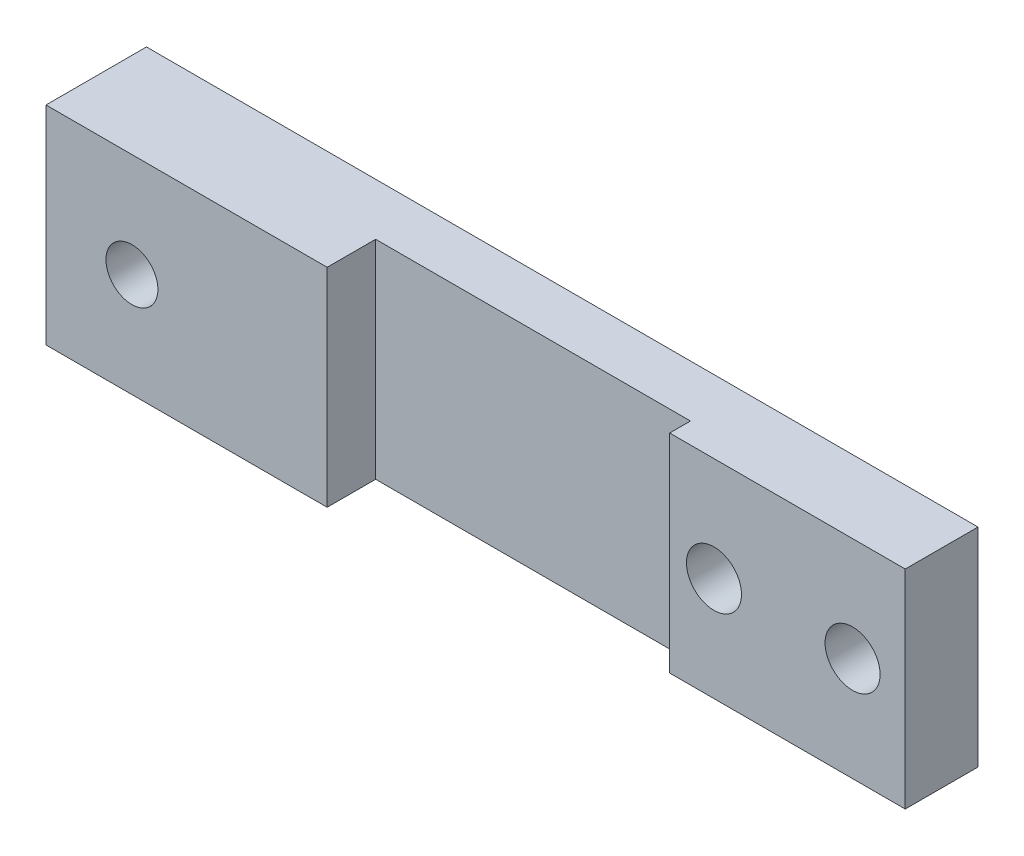
from build123d import *

# Parameters (mm, degrees)
SKETCH1_W                        = 152.4
SKETCH1_H                        = 38.1
BOSS_EXTRUDE1_DEPTH              = 9.525
SKETCH5_W                        = 43.18
SKETCH5_H                        = 38.1
BOSS_EXTRUDE3_DEPTH              = 3.81
SKETCH3_W                        = 5.0419
SKETCH3_H                        = 3.81
F_3_8_CLEARANCE_HOLE1_AT_2_COUNT = 2
F_3_8_CLEARANCE_HOLE1_AT_2_PITCH = 25.4
SKETCH4_W                        = 51.528477944
SKETCH4_H                        = 38.1
BOSS_EXTRUDE2_DEPTH              = 8.89
F_3_8_CLEARANCE_HOLE3_D          = 10.0838
SKETCH10_R                       = 4.7625
CUT_EXTRUDE1_DEPTH               = 19.415


with BuildPart() as part:
    # Sketch1 → Boss-Extrude1 (new body)
    with BuildSketch(Plane.XY):
        Rectangle(SKETCH1_W, SKETCH1_H)
    extrude(amount=BOSS_EXTRUDE1_DEPTH)

    # Sketch5 → Boss-Extrude3 (add)
    with BuildSketch(Plane.XY.offset(9.525)):
        with Locations((54.61, 0)):
            Rectangle(SKETCH5_W, SKETCH5_H)
    extrude(amount=BOSS_EXTRUDE3_DEPTH)

    # Sketch3 → 3/8 Clearance Hole1 (revolve, cut)
    with BuildSketch(Plane(origin=(41.148, 0, 9.525), x_dir=(0, 1, 0), z_dir=(1, 0, 0))):
        with Locations((2.52095, 1.905)):
            Rectangle(SKETCH3_W, SKETCH3_H)
    f_3_8_clearance_hole1 = revolve(axis=Axis((41.148, 0, 3.175), (0, 0, 1)), mode=Mode.SUBTRACT)

    # 3/8 Clearance Hole1 at 2: 3/8 Clearance Hole1 ×2
    with Locations(*[(i * F_3_8_CLEARANCE_HOLE1_AT_2_PITCH, 0, 0) for i in range(1, F_3_8_CLEARANCE_HOLE1_AT_2_COUNT)]):
        add(f_3_8_clearance_hole1, mode=Mode.SUBTRACT)

    # Sketch4 → Boss-Extrude2 (add)
    with BuildSketch(Plane.XY.offset(9.525)):
        with Locations((-50.435761028, 0)):
            Rectangle(SKETCH4_W, SKETCH4_H)
    extrude(amount=BOSS_EXTRUDE2_DEPTH)

    # 3/8 Clearance Hole3 (through all)
    with Locations(Plane(origin=(0, 0, 0), x_dir=(-1, 0, 0), z_dir=(0, 0, -1))):
        with Locations((-66.548, 0), (-41.148, 0)):
            Hole(F_3_8_CLEARANCE_HOLE3_D / 2)

    # Sketch10 → Cut-Extrude1 (cut, through all)
    with BuildSketch(Plane.XY.offset(18.415)):
        with Locations((-60.452, 0)):
            Circle(SKETCH10_R)
    extrude(amount=-CUT_EXTRUDE1_DEPTH, mode=Mode.SUBTRACT)


solid = part.part
